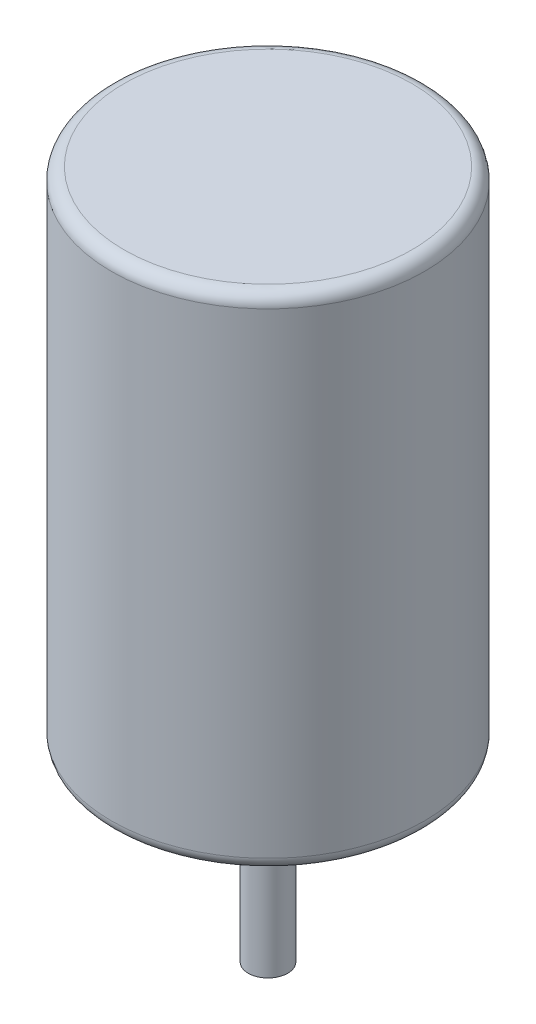
from build123d import *

# Parameters (mm, degrees)
SKETCH1_R           = 25
BOSS_EXTRUDE1_DEPTH = 80
SKETCH1_2_R         = 3.15
BOSS_EXTRUDE2_DEPTH = 30
FILLET1_R           = 2


with BuildPart() as part:
    # Sketch1 → Boss-Extrude1 (new body)
    with BuildSketch(Plane(origin=(0, 0, 0), x_dir=(1, 0, 0), z_dir=(0, 1, 0))):
        Circle(SKETCH1_R)
    extrude(amount=BOSS_EXTRUDE1_DEPTH)

    # Fillet1
    fillet1_edges = [part.edges().sort_by_distance(p)[0] for p in [
        (-25, 0, 0),
        (-25, 80, 0),
    ]]
    fillet(fillet1_edges, radius=FILLET1_R)


with BuildPart() as body_2:
    # Sketch1_2 → Boss-Extrude2 (new body)
    with BuildSketch(Plane(origin=(0, 0, 0), x_dir=(1, 0, 0), z_dir=(0, 1, 0))):
        Circle(SKETCH1_2_R)
    extrude(amount=-BOSS_EXTRUDE2_DEPTH)


solid = Compound([part.part, body_2.part])
